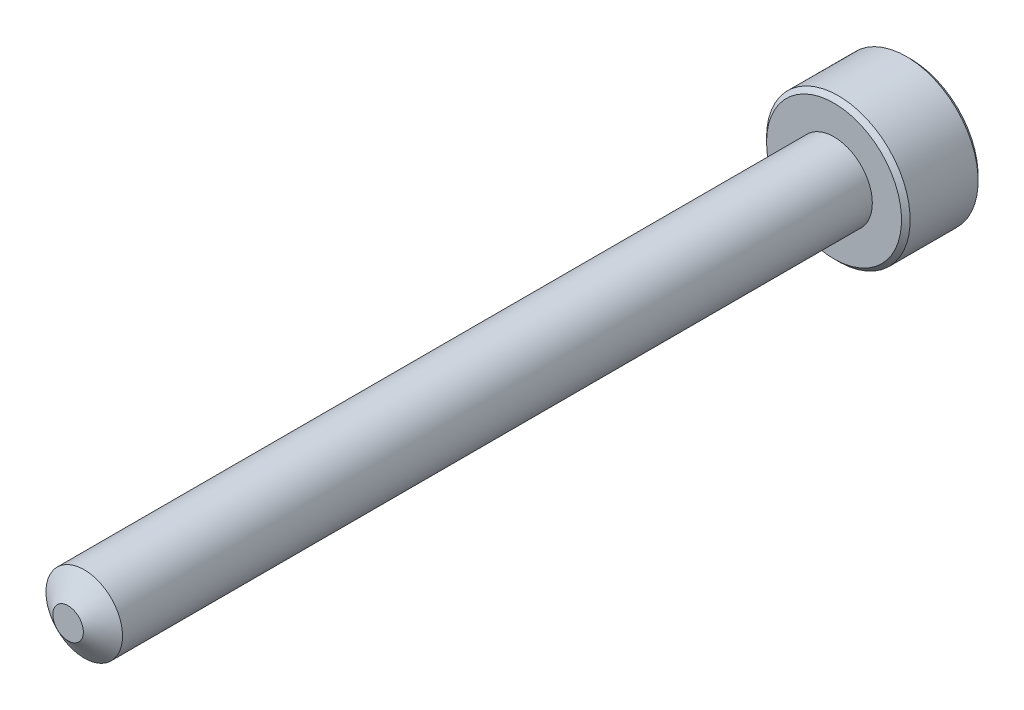
from build123d import *

# Parameters (mm, degrees)
SKETCH1_R          = 0.8
EXTRUDE1_DEPTH     = 16
SKETCH6_R          = 1.5
EXTRUDE2_DEPTH     = 1.6
CUT_EXTRUDE1_DEPTH = 1.125
CHAMFER1_SIZE      = 0.09


with BuildPart() as part:
    # Sketch1 → Extrude1 (new body)
    with BuildSketch(Plane.XY):
        Circle(SKETCH1_R)
    extrude(amount=-EXTRUDE1_DEPTH)

    # Sketch4 → Cut-Revolve1 (revolve, cut)
    with BuildSketch(Plane(origin=(0, 0, 0), x_dir=(0, 0, -1), z_dir=(1, 0, 0))):
        Polygon((0.337032063, 0.8), (0, 0.318668332), (0, 0.8), align=None)
    revolve(axis=Axis((0, 0, 0), (0, 0, -1)), mode=Mode.SUBTRACT)

    # Sketch6 → Extrude2 (add)
    with BuildSketch(Plane(origin=(0, 0, -16), x_dir=(-1, 0, 0), z_dir=(0, 0, -1))):
        Circle(SKETCH6_R)
    extrude(amount=EXTRUDE2_DEPTH)

    # Sketch7 → Cut-Extrude1 (cut)
    with BuildSketch(Plane(origin=(0, 0, -17.6), x_dir=(-1, 0, 0), z_dir=(0, 0, -1))):
        Polygon((0, 0.866025404), (-0.75, 0.433012702), (-0.75, -0.433012702), (0, -0.866025404), (0.75, -0.433012702), (0.75, 0.433012702), align=None)
    extrude(amount=-CUT_EXTRUDE1_DEPTH, mode=Mode.SUBTRACT)

    # Cut-Extrude2 cone 1 section (through the dimple's axis) → Cut-Extrude2 (revolve, cut)
    with BuildSketch(Plane(origin=(0, 0, -17.6), x_dir=(0, 1, 0), z_dir=(1, 0, 0))):
        Polygon((0, 0), (0.866025404, 0), (0, 0.866025404), align=None)
    revolve(axis=Axis((0, 0, -17.6), (0, 0, 1)), mode=Mode.SUBTRACT)

    # Chamfer1
    chamfer1_edges = [part.edges().sort_by_distance(p)[0] for p in [
        (1.5, 0, -17.6),
        (1.5, 0, -16),
    ]]
    chamfer(chamfer1_edges, length=CHAMFER1_SIZE)

    # Sketch10 → Revolve1 (revolve)
    with BuildSketch(Plane(origin=(0, 0, 0), x_dir=(0, 0, -1), z_dir=(1, 0, 0))):
        Polygon((16, 0.8), (16, 0), (15.58112915, 0), (15.9125, 0.8), align=None)
    revolve(axis=Axis((0, 0, -16), (0, 0, 1)))


solid = part.part
